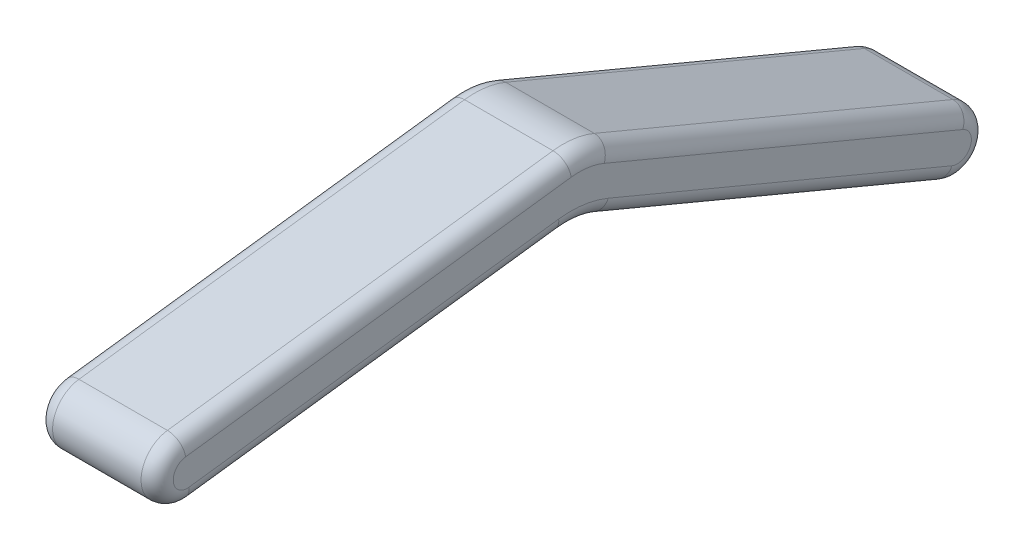
from build123d import *

# Parameters (mm, degrees)
BOSS_EXTRUDE1_DEPTH = 7.5
FILLET1_R           = 2


with BuildPart() as part:
    # Sketch1 → Boss-Extrude1 (new body, symmetric)
    with BuildSketch(Plane(origin=(0, 0, 0), x_dir=(0, 0, -1), z_dir=(1, 0, 0))):
        with BuildLine():
            Line((1.447085463, 3.459543852), (-43.135195924, 22.107774393))
            ThreePointArc((-43.135195924, 22.107774393), (-45.654406798, 22.792180206), (-48.264914902, 22.801245703))
            Line((-48.264914902, 22.801245703), (-96.198418413, 16.659946393))
            ThreePointArc((-96.198418413, 16.659946393), (-99.441454852, 12.463791647), (-95.245300106, 9.220755208))
            Line((-95.245300106, 9.220755208), (-49.305121866, 15.106667237))
            ThreePointArc((-49.305121866, 15.106667237), (-46.694613762, 15.09760174), (-44.175402888, 14.413195927))
            Line((-44.175402888, 14.413195927), (-1.447085463, -3.459543852))
            ThreePointArc((-1.447085463, -3.459543852), (3.459543852, -1.447085463), (1.447085463, 3.459543852))
        make_face()
    extrude(amount=BOSS_EXTRUDE1_DEPTH, both=True)

    # Fillet1
    fillet1_edges = [part.edges().sort_by_distance(p)[0] for p in [
        (-7.5, 12.783659122, 20.844055231),
        (-7.5, -1.447085463, -3.459543852),
        (-7.5, 5.476826038, 22.811244176),
        (-7.5, 15.09760174, 46.694613762),
        (7.5, -1.447085463, -3.459543852),
        (7.5, 12.783659122, 20.844055231),
        (7.5, 22.792180206, 45.654406798),
        (7.5, 19.730596048, 72.231666657),
        (7.5, 12.463791647, 99.441454852),
        (7.5, 12.163711222, 72.275210986),
        (7.5, 15.09760174, 46.694613762),
        (-7.5, 12.163711222, 72.275210986),
        (7.5, 5.476826038, 22.811244176),
        (-7.5, 12.463791647, 99.441454852),
        (-7.5, 19.730596048, 72.231666657),
        (-7.5, 22.792180206, 45.654406798),
    ]]
    fillet(fillet1_edges, radius=FILLET1_R)


solid = part.part
